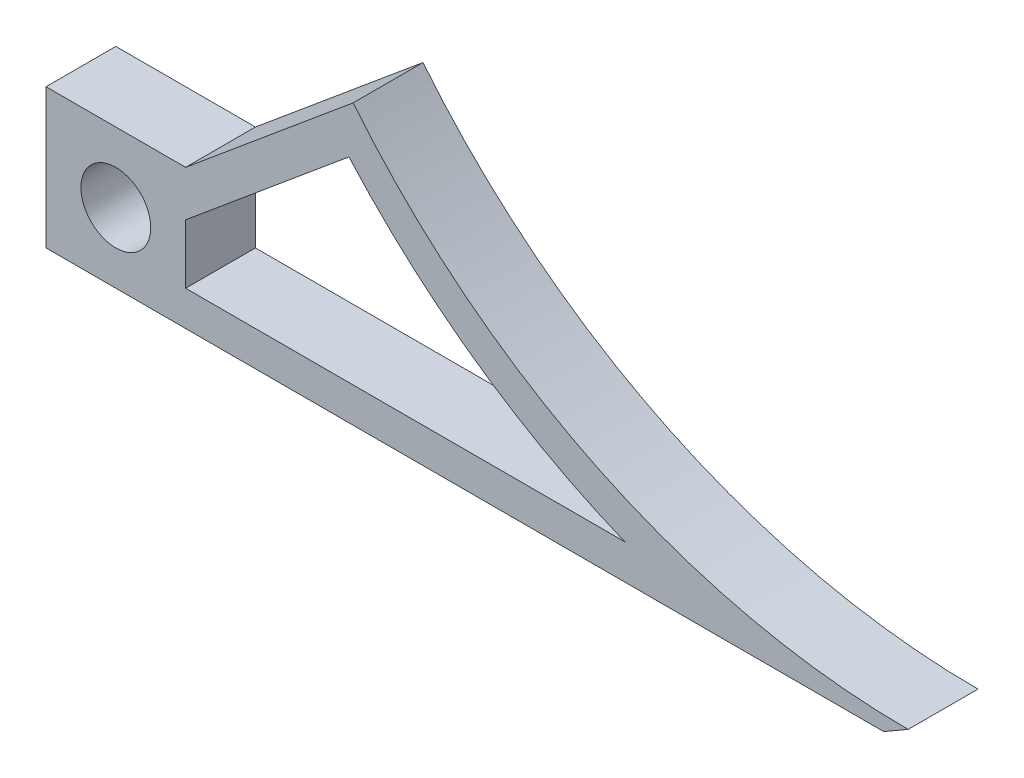
from build123d import *

# Parameters (mm, degrees)
SKETCH1_R           = 3.175
BOSS_EXTRUDE1_DEPTH = 6.35


with BuildPart() as part:
    # Sketch1 → Boss-Extrude1 (new body)
    with BuildSketch(Plane.XY):
        with BuildLine():
            Line((6.35, 6.35), (21.59, 19.05))
            ThreePointArc((21.59, 19.05), (44.100663682, 1.273044039), (72.075222755, -5.065267043))
            Line((72.075222755, -5.065267043), (69.85, -6.35))
            Line((69.85, -6.35), (6.35, -6.35))
            Line((6.35, -6.35), (-6.35, -6.35))
            Line((-6.35, -6.35), (-6.35, 6.35))
            Line((-6.35, 6.35), (6.35, 6.35))
        make_face()
        Circle(SKETCH1_R, mode=Mode.SUBTRACT)
        with BuildLine():
            Line((6.35, -3.175), (46.306849943, -3.175))
            ThreePointArc((46.306849943, -3.175), (32.739109843, 4.274408806), (21.204775898, 14.596056128))
            Line((21.204775898, 14.596056128), (6.35, 2.217076213))
            Line((6.35, 2.217076213), (6.35, -3.175))
        make_face(mode=Mode.SUBTRACT)
    extrude(amount=BOSS_EXTRUDE1_DEPTH)


solid = part.part
